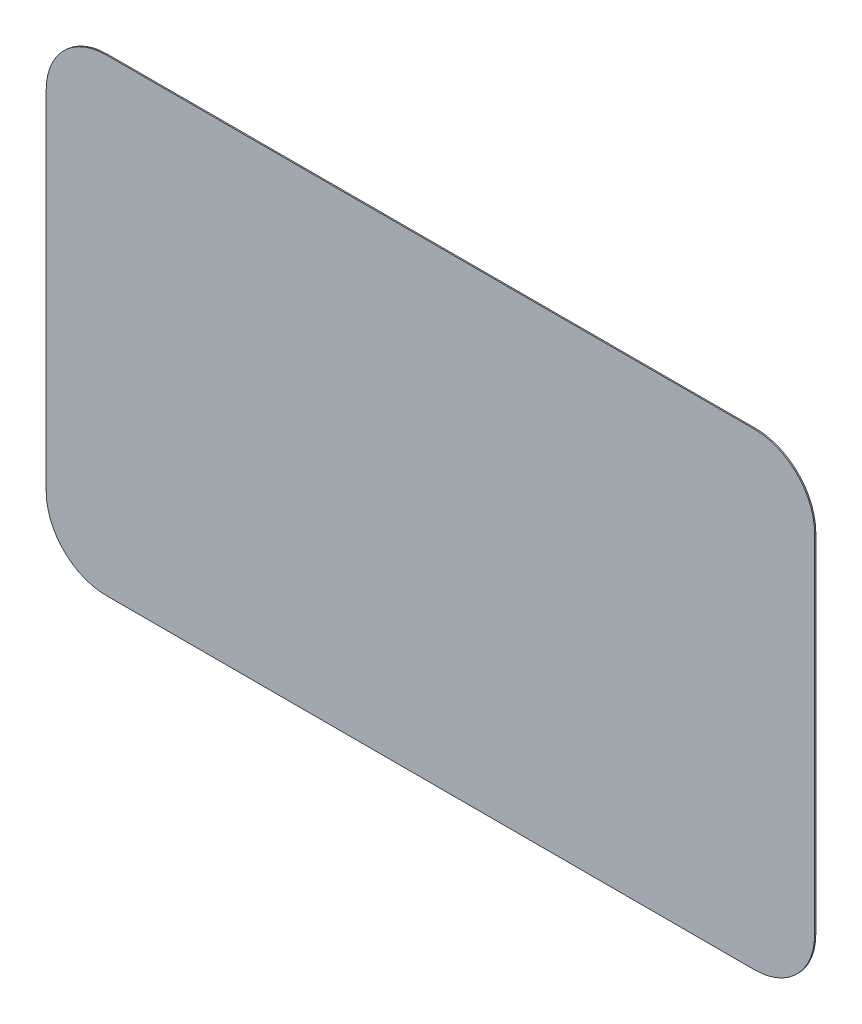
from build123d import *

# Parameters (mm, degrees)
BOSS_EXTRUDE1_DEPTH = 0.5
FILLET1_R           = 20
FILLET2_R           = 5
SKETCH5_W           = 85
SKETCH5_H           = 69.5
CUT_EXTRUDE1_DEPTH  = 98.5000001


with BuildPart() as part:
    # Sketch1 → Boss-Extrude1 (new body)
    with BuildSketch(Plane.XY):
        with BuildLine():
            Line((-135, -97.5), (135, -97.5))
            ThreePointArc((135, -97.5), (152.67766953, -90.17766953), (160, -72.5))
            Line((160, -72.5), (160, 72.5))
            ThreePointArc((160, 72.5), (152.67766953, 90.17766953), (135, 97.5))
            Line((135, 97.5), (-135, 97.5))
            ThreePointArc((-135, 97.5), (-152.67766953, 90.17766953), (-160, 72.5))
            Line((-160, 72.5), (-160, -72.5))
            ThreePointArc((-160, -72.5), (-152.67766953, -90.17766953), (-135, -97.5))
        make_face()
    extrude(amount=BOSS_EXTRUDE1_DEPTH)

    # Sketch3 → Loft1 section 0
    with BuildSketch(Plane(origin=(0, 0, 0), x_dir=(-1, 0, 0), z_dir=(0, 0, -1))):
        with BuildLine():
            Line((-135, -97.5), (-75, -97.5))
            Line((-75, -97.5), (-75, -37.5))
            ThreePointArc((-75, -37.5), (-82.32233047, -19.82233047), (-100, -12.5))
            Line((-100, -12.5), (-160, -12.5))
            Line((-160, -12.5), (-160, -72.5))
            ThreePointArc((-160, -72.5), (-152.67766953, -90.17766953), (-135, -97.5))
        make_face()
    # Sketch4 → Loft1 section 1
    with BuildSketch(Plane.XY.offset(-69.5)):
        with BuildLine():
            Line((153, -72.5), (153, -19.5))
            Line((153, -19.5), (100, -19.5))
            ThreePointArc((100, -19.5), (87.272077939, -24.772077939), (82, -37.5))
            Line((82, -37.5), (82, -90.5))
            Line((82, -90.5), (135, -90.5))
            ThreePointArc((135, -90.5), (147.727922061, -85.227922061), (153, -72.5))
        make_face()
    loft()

    # Fillet1
    fillet1_edges = [part.edges().sort_by_distance(p)[0] for p in [
        (82, -64, -69.5),
        (126.5, -19.5, -69.5),
    ]]
    fillet(fillet1_edges, radius=FILLET1_R)

    # Fillet2
    fillet2_edges = [part.edges().sort_by_distance(p)[0] for p in [
        (77.593739129, -94.906260871, -25.75212421),
        (86.655220253, -91.021861498, -64.318660839),
        (117.543397663, -90.5, -69.5),
        (153, -55.043320694, -69.5),
        (147.727922061, -85.227922061, -69.5),
        (153.521863591, -24.155150727, -64.318640061),
        (157.406260281, -15.093739719, -25.752130071),
    ]]
    fillet(fillet2_edges, radius=FILLET2_R)

    # Sketch5 → Cut-Extrude1 (cut, through all)
    with BuildSketch(Plane(origin=(0, 0, 0), x_dir=(1, 0, 0), z_dir=(0, 1, 0))):
        with Locations((117.5, 34.75)):
            Rectangle(SKETCH5_W, SKETCH5_H)
    extrude(amount=-CUT_EXTRUDE1_DEPTH, mode=Mode.SUBTRACT)


solid = part.part
